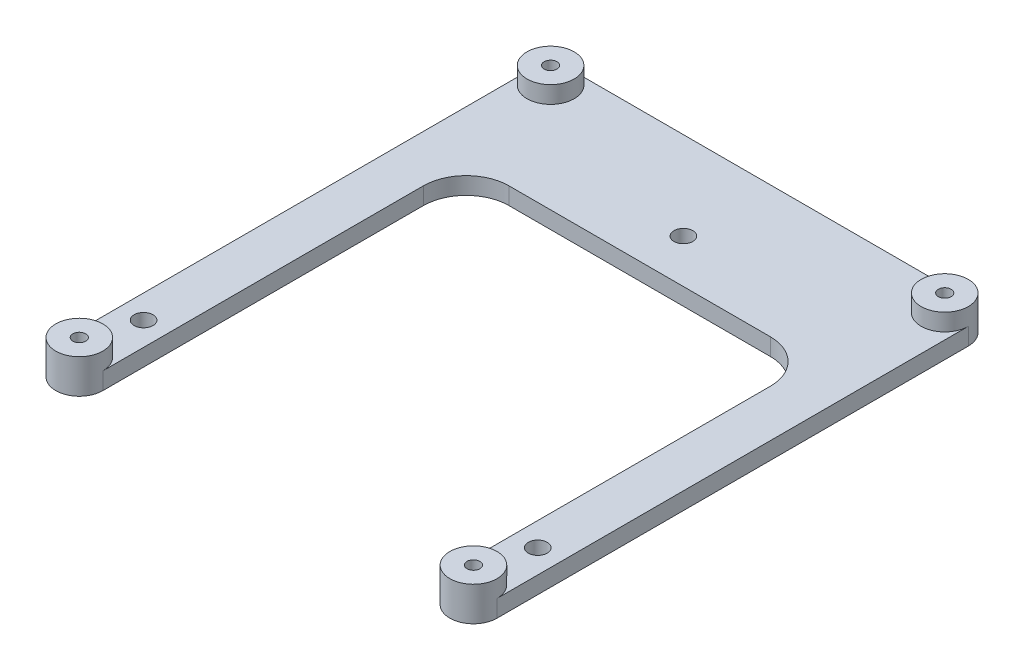
from build123d import *

# Parameters (mm, degrees)
SKETCH2_W               = 54
SKETCH2_H               = 63
SKETCH2_R               = 0.75
BOSS_EXTRUDE1_DEPTH     = 2
SKETCH1_R               = 1.1
CUT_EXTRUDE2_DEPTH      = 3
CUT_EXTRUDE2_DEPTH_BACK = 1
SKETCH3_R               = 2.75
SKETCH3_R_2             = 0.75
BOSS_EXTRUDE2_DEPTH     = 2
SKETCH4_OUTSIDE_W       = 72.614
SKETCH4_OUTSIDE_H       = 81.614
CUT_EXTRUDE3_DEPTH      = 3
CUT_EXTRUDE3_DEPTH_BACK = 3
CUT_EXTRUDE4_DEPTH      = 3
CUT_EXTRUDE4_DEPTH_BACK = 3
FILLET1_R               = 5


with BuildPart() as part:
    # Sketch2 → Boss-Extrude1 (new body)
    with BuildSketch(Plane(origin=(0, 0, 0), x_dir=(1, 0, 0), z_dir=(0, 1, 0))):
        with Locations((23, 20)):
            Rectangle(SKETCH2_W, SKETCH2_H)
        with Locations((46, -7.5)):
            Circle(SKETCH2_R, mode=Mode.SUBTRACT)
        with Locations((46, 47.5)):
            Circle(SKETCH2_R, mode=Mode.SUBTRACT)
        with Locations((0, 47.5)):
            Circle(SKETCH2_R, mode=Mode.SUBTRACT)
        with Locations((0, -7.5)):
            Circle(SKETCH2_R, mode=Mode.SUBTRACT)
    extrude(amount=BOSS_EXTRUDE1_DEPTH)

    # Sketch1 → Cut-Extrude2 (cut, two sides)
    with BuildSketch(Plane(origin=(0, 0, 0), x_dir=(1, 0, 0), z_dir=(0, 1, 0))) as cut_extrude2_sk:
        Circle(SKETCH1_R)
        with Locations((46, 0)):
            Circle(SKETCH1_R)
        with Locations((23, 40)):
            Circle(SKETCH1_R)
    extrude(amount=CUT_EXTRUDE2_DEPTH, mode=Mode.SUBTRACT)
    extrude(cut_extrude2_sk.sketch, amount=-CUT_EXTRUDE2_DEPTH_BACK, mode=Mode.SUBTRACT)

    # Sketch3 → Boss-Extrude2 (add)
    with BuildSketch(Plane(origin=(0, 2, 0), x_dir=(1, 0, 0), z_dir=(0, 1, 0))):
        with Locations((0, -7.5)):
            Circle(SKETCH3_R)
        with Locations((0, -7.5)):
            Circle(SKETCH3_R_2, mode=Mode.SUBTRACT)
        with Locations((46, -7.5)):
            Circle(SKETCH3_R)
        with Locations((46, -7.5)):
            Circle(SKETCH3_R_2, mode=Mode.SUBTRACT)
        with Locations((46, 47.5)):
            Circle(SKETCH3_R)
        with Locations((46, 47.5)):
            Circle(SKETCH3_R_2, mode=Mode.SUBTRACT)
        with Locations((0, 47.5)):
            Circle(SKETCH3_R)
        with Locations((0, 47.5)):
            Circle(SKETCH3_R_2, mode=Mode.SUBTRACT)
    extrude(amount=BOSS_EXTRUDE2_DEPTH)

    # Sketch4 outside → Cut-Extrude3 (cut, two sides)
    with BuildSketch(Plane(origin=(0, 2, 0), x_dir=(1, 0, 0), z_dir=(0, 1, 0))) as cut_extrude3_sk:
        with Locations((23, 20)):
            Rectangle(SKETCH4_OUTSIDE_W, SKETCH4_OUTSIDE_H)
        with BuildLine():
            Line((0, -10.25), (46, -10.25))
            ThreePointArc((46, -10.25), (47.944543648, -9.444543648), (48.75, -7.5))
            Line((48.75, -7.5), (48.75, 47.5))
            ThreePointArc((48.75, 47.5), (47.944543648, 49.444543648), (46, 50.25))
            Line((46, 50.25), (0, 50.25))
            ThreePointArc((0, 50.25), (-1.944543648, 49.444543648), (-2.75, 47.5))
            Line((-2.75, 47.5), (-2.75, -7.5))
            ThreePointArc((-2.75, -7.5), (-1.944543648, -9.444543648), (0, -10.25))
        make_face(mode=Mode.SUBTRACT)
    extrude(amount=CUT_EXTRUDE3_DEPTH, mode=Mode.SUBTRACT)
    extrude(cut_extrude3_sk.sketch, amount=-CUT_EXTRUDE3_DEPTH_BACK, mode=Mode.SUBTRACT)

    # Sketch5 → Cut-Extrude4 (cut, two sides)
    with BuildSketch(Plane(origin=(0, 2, 0), x_dir=(1, 0, 0), z_dir=(0, 1, 0))) as cut_extrude4_sk:
        with BuildLine():
            Line((2.75, 34.9), (2.75, -7.5))
            ThreePointArc((2.75, -7.5), (1.944543648, -9.444543648), (0, -10.25))
            Line((0, -10.25), (46, -10.25))
            ThreePointArc((46, -10.25), (44.055456352, -9.444543648), (43.25, -7.5))
            Line((43.25, -7.5), (43.25, 34.9))
            Line((43.25, 34.9), (2.75, 34.9))
        make_face()
    extrude(amount=CUT_EXTRUDE4_DEPTH, mode=Mode.SUBTRACT)
    extrude(cut_extrude4_sk.sketch, amount=-CUT_EXTRUDE4_DEPTH_BACK, mode=Mode.SUBTRACT)

    # Fillet1
    fillet1_edges = [part.edges().sort_by_distance(p)[0] for p in [
        (2.75, 1, -34.9),
        (43.25, 1, -34.9),
    ]]
    fillet(fillet1_edges, radius=FILLET1_R)


solid = part.part
